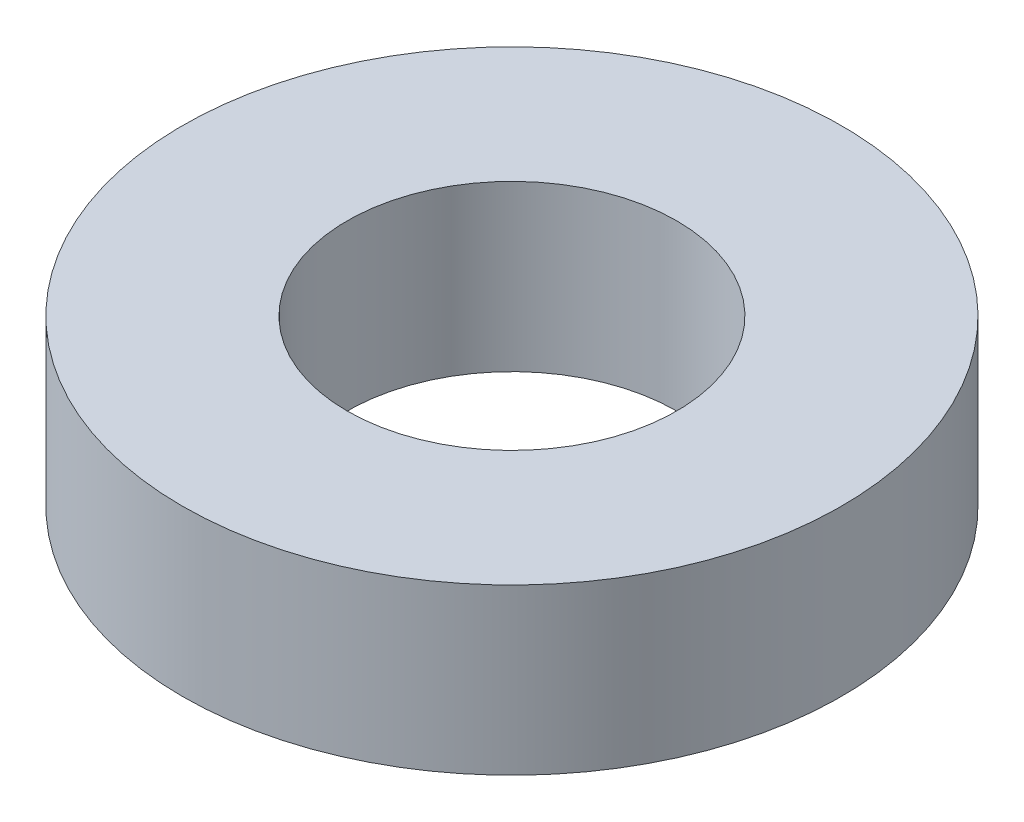
from build123d import *

# Parameters (mm, degrees)
SKETCH1_R           = 3
BOSS_EXTRUDE1_DEPTH = 1.5
SKETCH2_R           = 1.5
CUT_EXTRUDE1_DEPTH  = 1.5


with BuildPart() as part:
    # Sketch1 → Boss-Extrude1 (new body)
    with BuildSketch(Plane(origin=(0, 0, 0), x_dir=(1, 0, 0), z_dir=(0, 1, 0))):
        with Locations(Location((0, 0, 0), (0, 0, 270))):  # turned: the seam where the file's is
            Circle(SKETCH1_R)
    extrude(amount=BOSS_EXTRUDE1_DEPTH)

    # Sketch2 → Cut-Extrude1 (cut)
    with BuildSketch(Plane(origin=(0, 1.5, 0), x_dir=(1, 0, 0), z_dir=(0, 1, 0))):
        with Locations(Location((0, 0, 0), (0, 0, 270))):  # turned: the seam where the file's is
            Circle(SKETCH2_R)
    extrude(amount=-CUT_EXTRUDE1_DEPTH, mode=Mode.SUBTRACT)


solid = part.part
